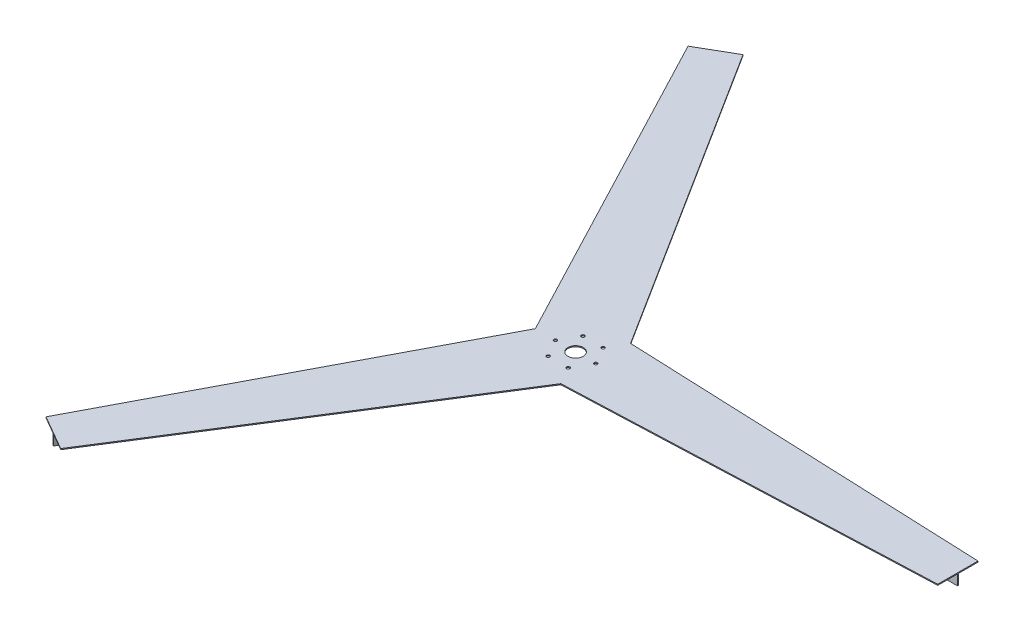
from build123d import *

# Parameters (mm, degrees)
CROQUIS1_R              = 19.05
SALIENTE_EXTRUIR3_DEPTH = 2.5
CROQUIS2_W              = 885
CROQUIS2_H              = 2.5
SALIENTE_EXTRUIR4_DEPTH = 25.4
CROQUIS4_R              = 4
CORTAR_EXTRUIR1_DEPTH   = 2.54


with BuildPart() as part:
    # Croquis1 → Saliente-Extruir3 (new body)
    with BuildSketch(Plane(origin=(0, 0, 0), x_dir=(1, 0, 0), z_dir=(0, 1, 0))):
        Polygon((-431.698729811, -847.724133595), (-518.301270189, -797.724133595), (-100, 0), (-518.301270189, 797.724133595), (-431.698729811, 847.724133595), (50, 86.602540378), (950, 50), (950, -50), (50, -86.602540378), align=None)
        Circle(CROQUIS1_R, mode=Mode.SUBTRACT)
    extrude(amount=SALIENTE_EXTRUIR3_DEPTH)

    # Croquis2 → Saliente-Extruir4 (add)
    with BuildSketch(Plane.XZ):
        with Locations((507.5, 0)):
            Rectangle(CROQUIS2_W, CROQUIS2_H)
        Polygon((-473.917468245, -823.349133595), (-31.417468245, -56.916651246), (-33.582531755, -55.666651246), (-476.082531755, -822.099133595), align=None)
        Polygon((-476.082531755, 822.099133595), (-33.582531755, 55.666651246), (-31.417468245, 56.916651246), (-473.917468245, 823.349133595), align=None)
    extrude(amount=SALIENTE_EXTRUIR4_DEPTH)

    # Croquis4 → Cortar-Extruir1 (cut)
    with BuildSketch(Plane(origin=(0, 2.5, 0), x_dir=(1, 0, 0), z_dir=(0, 1, 0))):
        with Locations((25, -43.301270189)):
            Circle(CROQUIS4_R)
        with Locations((-25, -43.301270189)):
            Circle(CROQUIS4_R)
        with Locations((-50, 0)):
            Circle(CROQUIS4_R)
        with Locations((-25, 43.301270189)):
            Circle(CROQUIS4_R)
        with Locations((25, 43.301270189)):
            Circle(CROQUIS4_R)
        with Locations((50, 0)):
            Circle(CROQUIS4_R)
    extrude(amount=-CORTAR_EXTRUIR1_DEPTH, mode=Mode.SUBTRACT)


solid = part.part
